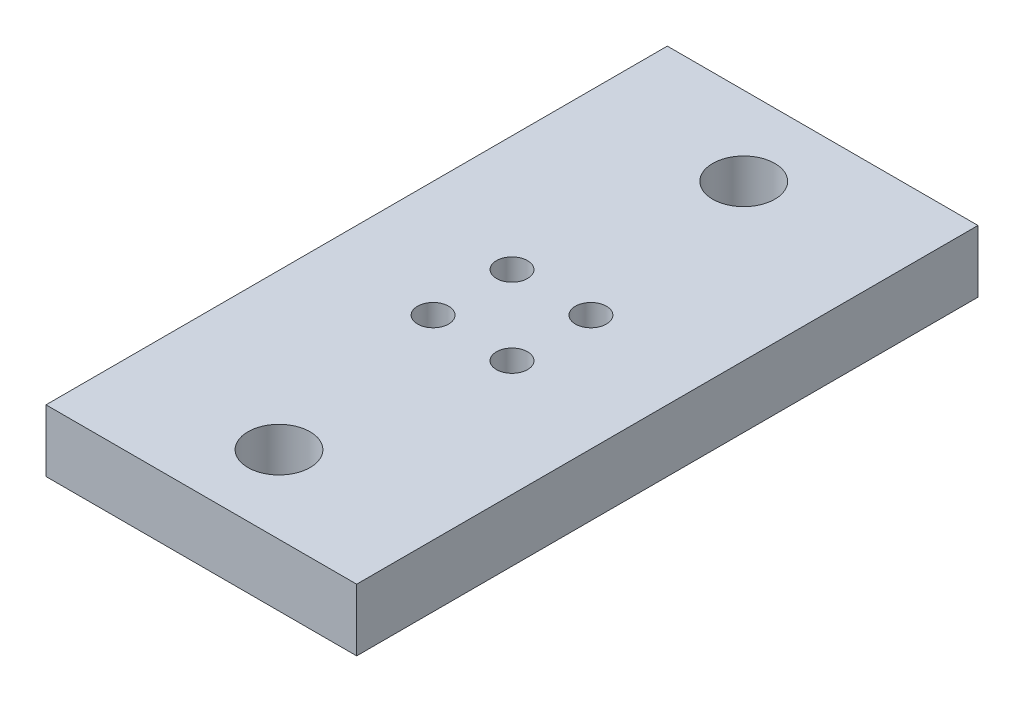
from build123d import *

# Parameters (mm, degrees)
CROQUIS1_W              = 10
CROQUIS1_H              = 20
SALIENTE_EXTRUIR1_DEPTH = 2
CROQUIS2_R              = 1
CROQUIS2_R_2            = 0.5
CORTAR_EXTRUIR1_DEPTH   = 3


with BuildPart() as part:
    # Croquis1 → Saliente-Extruir1 (new body)
    with BuildSketch(Plane(origin=(0, 0, 0), x_dir=(1, 0, 0), z_dir=(0, 1, 0))):
        Rectangle(CROQUIS1_W, CROQUIS1_H)
    extrude(amount=SALIENTE_EXTRUIR1_DEPTH)

    # Croquis2 → Cortar-Extruir1 (cut, through all)
    with BuildSketch(Plane(origin=(0, 2, 0), x_dir=(1, 0, 0), z_dir=(0, 1, 0))):
        with Locations((0, 7.46)):
            Circle(CROQUIS2_R)
        with Locations((0, -7.5)):
            Circle(CROQUIS2_R)
        with Locations((1.27, 1.27)):
            Circle(CROQUIS2_R_2)
        with Locations((-1.27, 1.27)):
            Circle(CROQUIS2_R_2)
        with Locations((-1.27, -1.27)):
            Circle(CROQUIS2_R_2)
        with Locations((1.27, -1.27)):
            Circle(CROQUIS2_R_2)
    extrude(amount=-CORTAR_EXTRUIR1_DEPTH, mode=Mode.SUBTRACT)


solid = part.part
